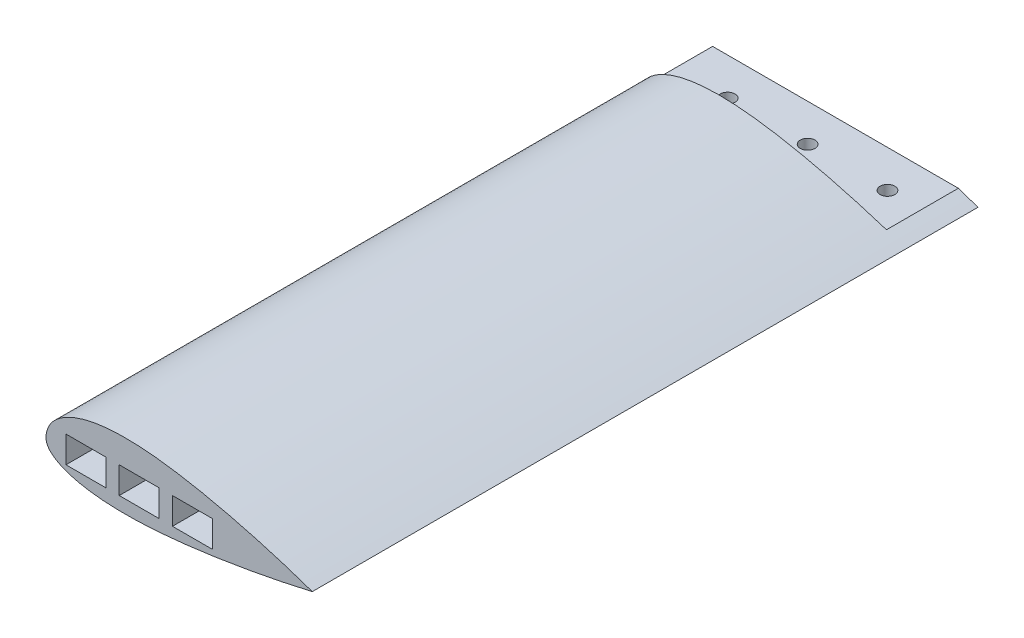
from build123d import *

# Parameters (mm, degrees)
BOSS_EXTRUDE1_DEPTH     = 125
CUT_EXTRUDE1_DEPTH      = 110
CUT_EXTRUDE1_DEPTH_BACK = 90
SKETCH9_OUTSIDE_W       = 156.08
SKETCH9_OUTSIDE_H       = 80.93
SKETCH9_OUTSIDE_W_2     = 100
SKETCH9_OUTSIDE_H_2     = 5
CUT_EXTRUDE2_DEPTH      = 27
M5_CLEARANCE_HOLE1_D    = 5.5
SKETCH15_W              = 15
SKETCH15_H              = 10
CUT_EXTRUDE3_DEPTH      = 10


with BuildPart() as part:
    # Sketch1 → Boss-Extrude1 (new body, symmetric)
    with BuildSketch(Plane.XY):
        with BuildLine():
            add(Edge.make_bspline(
                [(0, 0), (0.000850995, 0.329659199), (0.029549865, 0.927472015), (0.14385133, 1.796745902), (0.437026819, 2.918116545), (0.854897816, 3.99067399), (1.431457873, 5.075606208), (2.192315162, 6.177305776), (3.200330795, 7.329994922), (4.495933807, 8.510625759), (6.154032841, 9.714948919), (8.274086435, 10.929186229), (10.956963281, 12.114631433), (14.147653492, 13.152534318), (18.040460609, 14.036328853), (23.13432232, 14.736569605), (29.235682959, 15.027445823), (35.337980191, 14.824799668), (41.101061226, 14.313753112), (46.84100573, 13.596774566), (51.603718071, 12.850513756), (56.345578755, 11.983351698), (61.067148387, 11.013921336), (64.832774323, 10.182970339), (68.586460194, 9.301464098), (72.329426272, 8.372556112), (76.059801155, 7.399362237), (79.315748534, 6.509324276), (82.095955547, 5.720960272), (84.412746103, 5.044415193), (86.253737616, 4.495737821), (88.110746108, 3.929395104), (89.928948501, 3.364622885), (91.806033909, 2.766575591), (93.571042413, 2.195551738), (95.520153622, 1.546294126), (97.13830136, 1.000944859), (98.775140125, 0.431667147), (99.586664269, 0.14652965), (100.000220498, 0)],
                knots=[0, 0, 0, 0, 0, 0.011046069, 0.020081733, 0.029325805, 0.03880189, 0.049580055, 0.06120956, 0.074146174, 0.090070544, 0.108265326, 0.129826997, 0.155964864, 0.18830697, 0.220649281, 0.263591413, 0.32827592, 0.392960436, 0.425302696, 0.457644956, 0.52232947, 0.55467173, 0.58701399, 0.619356253, 0.651698515, 0.684040775, 0.716383035, 0.748725291, 0.764896419, 0.781067547, 0.797238677, 0.813409806, 0.829580935, 0.845752065, 0.861923198, 0.878094331, 0.894265464, 0.910433902, 0.910433902, 0.910433902, 0.910433902, 0.910433902], degree=4))
            add(Edge.make_bspline(
                [(0, 0), (0.000283694, -0.169267254), (0.015976794, -0.461371136), (0.077487025, -0.88514164), (0.233270026, -1.435649885), (0.451244669, -1.960918505), (0.763020391, -2.515682909), (1.196819683, -3.111846412), (1.800946429, -3.766711239), (2.645862845, -4.495413172), (3.845009807, -5.315163118), (5.520192869, -6.210587445), (7.890487327, -7.180714875), (10.947062049, -8.096276481), (15.429604607, -9.039640979), (21.207967366, -9.730011133), (27.977535992, -10.02746215), (35.648602876, -9.889128299), (42.346864335, -9.465706657), (48.074827103, -8.93985543), (53.791477179, -8.306095929), (59.496830619, -7.576550222), (65.188499989, -6.746051578), (70.86666832, -5.830240622), (75.589869863, -5.014181774), (79.362447213, -4.33071773), (82.659602016, -3.705830248), (85.480106996, -3.151491524), (87.596226543, -2.723280533), (89.000489113, -2.434123885), (90.181059485, -2.187185496), (91.104029231, -1.992562417), (92.305099816, -1.735390328), (93.655404022, -1.443860687), (95.389810689, -1.059643077), (97.102663756, -0.674849293), (98.714450572, -0.301843412), (99.575627153, -0.100232022), (100.000220498, 0)],
                knots=[0, 0, 0, 0, 0, 0.005887152, 0.010193359, 0.014866851, 0.019889426, 0.025655397, 0.032314697, 0.040497527, 0.050864902, 0.064448179, 0.082823086, 0.106555664, 0.139953895, 0.175459216, 0.242255956, 0.309052716, 0.375849477, 0.442646237, 0.47604462, 0.509443003, 0.576239764, 0.643036527, 0.676434909, 0.709833291, 0.743231671, 0.77663005, 0.793329242, 0.810028433, 0.818378029, 0.826727624, 0.83507722, 0.843426816, 0.860126007, 0.876825198, 0.893524389, 0.91022358, 0.91022358, 0.91022358, 0.91022358, 0.91022358], degree=4))
        make_face()
    extrude(amount=BOSS_EXTRUDE1_DEPTH, both=True)

    # Sketch6 → Cut-Extrude1 (cut, two sides)
    with BuildSketch(Plane.XY) as cut_extrude1_sk:
        with BuildLine():
            add(Edge.make_bspline(
                [(5.003866411, 0.16593331), (5.021771107, 0.603167174), (5.179582681, 1.45668418), (5.828059264, 2.731623867), (6.970434665, 4.055197794), (9.059941641, 5.70999826), (12.439790451, 7.406031049), (17.102385774, 8.772586441), (22.086939339, 9.580996278), (28.969887571, 10.04915127), (37.811358565, 9.719164197), (48.519550578, 8.365627259), (62.800967104, 5.688073766), (73.468720144, 2.987314718), (80.492223408, 0.975075783)],
                knots=[0.003107056, 0.003107056, 0.003107056, 0.003107056, 0.026472192, 0.049837329, 0.073202466, 0.096567602, 0.143297876, 0.190028149, 0.236758422, 0.283488695, 0.376949242, 0.470409788, 0.563870335, 0.750791428, 0.750791428, 0.750791428, 0.750791428], degree=3))
            add(Edge.make_bspline(
                [(80.492223408, 0.975075783), (73.808709309, -0.294311553), (63.724097701, -1.995472923), (50.2739718, -3.721966825), (40.201550005, -4.64981718), (31.854573956, -4.99623266), (25.257558055, -4.894657534), (20.376304938, -4.583057975), (16.407020376, -4.077297068), (13.341823588, -3.482519629), (11.126614852, -2.928004065), (9.036775347, -2.250698534), (7.465669402, -1.576012545), (6.39422808, -0.985208256), (5.718999313, -0.532122097), (5.309123649, -0.182799424), (5.089567118, 0.053028449), (5.034725373, 0.122545069), (5.003866411, 0.16593331)],
                knots=[0.025550827, 0.025550827, 0.025550827, 0.025550827, 0.20536823, 0.295276931, 0.385185632, 0.475094334, 0.520048685, 0.565003035, 0.609957386, 0.632434561, 0.654911737, 0.677388912, 0.699866088, 0.711104675, 0.722343263, 0.733581851, 0.739201144, 0.744820438, 0.744820438, 0.744820438, 0.744820438], degree=3))
        make_face()
    extrude(amount=CUT_EXTRUDE1_DEPTH, mode=Mode.SUBTRACT)
    extrude(cut_extrude1_sk.sketch, amount=-CUT_EXTRUDE1_DEPTH_BACK, mode=Mode.SUBTRACT)

    # Sketch9 outside → Cut-Extrude2 (cut)
    with BuildSketch(Plane.XY.offset(-125)):
        with Locations((50, 2.485)):
            Rectangle(SKETCH9_OUTSIDE_W, SKETCH9_OUTSIDE_H)
        with Locations((50, 0)):
            Rectangle(SKETCH9_OUTSIDE_W_2, SKETCH9_OUTSIDE_H_2, mode=Mode.SUBTRACT)
    extrude(amount=CUT_EXTRUDE2_DEPTH, mode=Mode.SUBTRACT)

    # M5 Clearance Hole1 (through all)
    with Locations(Plane(origin=(0, 2.5, 0), x_dir=(1, 0, 0), z_dir=(0, 1, 0))):
        with Locations((20.000220498, 111), (80.000220498, 111), (50.000220498, 111)):
            Hole(M5_CLEARANCE_HOLE1_D / 2)

    # Sketch15 → Cut-Extrude3 (cut)
    with BuildSketch(Plane.XY.offset(125)):
        with Locations((35, 0)):
            Rectangle(SKETCH15_W, SKETCH15_H)
        with Locations((15, 0)):
            Rectangle(SKETCH15_W, SKETCH15_H)
        with Locations((55, 0)):
            Rectangle(SKETCH15_W, SKETCH15_H)
    extrude(amount=-CUT_EXTRUDE3_DEPTH, mode=Mode.SUBTRACT)


solid = part.part
